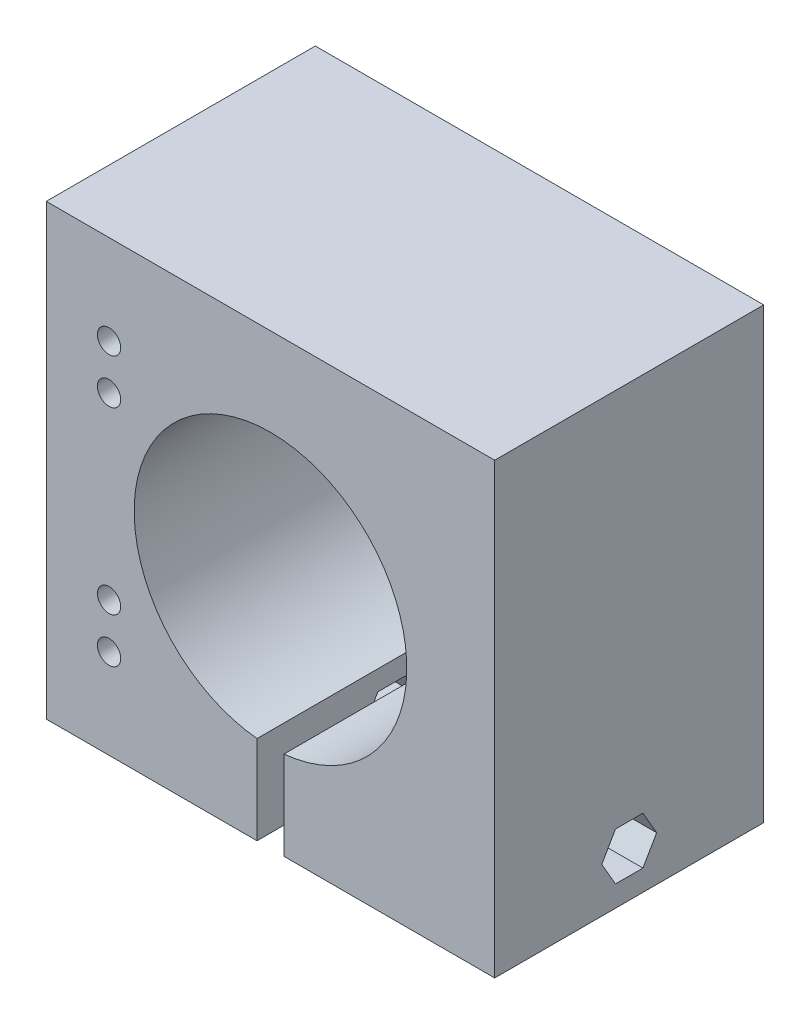
from build123d import *

# Parameters (mm, degrees)
SKETCH1_W           = 50
SKETCH1_H           = 50
SKETCH1_R           = 15.2
SKETCH1_R_2         = 1.3
BOSS_EXTRUDE1_DEPTH = 30
CUT_EXTRUDE1_REACH  = 32
SKETCH2_W           = 3
SKETCH2_H           = 11.709133009
CUT_EXTRUDE2_DEPTH  = 54
CUT_EXTRUDE3_DEPTH  = 5


with BuildPart() as part:
    # Sketch1 → Boss-Extrude1 (new body)
    with BuildSketch(Plane.XY):
        with Locations((25, 25)):
            Rectangle(SKETCH1_W, SKETCH1_H)
        with Locations((25, 25)):
            Circle(SKETCH1_R, mode=Mode.SUBTRACT)
        with Locations((7, 15)):
            Circle(SKETCH1_R_2, mode=Mode.SUBTRACT)
        with Locations((7, 40)):
            Circle(SKETCH1_R_2, mode=Mode.SUBTRACT)
        with Locations((7, 10)):
            Circle(SKETCH1_R_2, mode=Mode.SUBTRACT)
        with Locations((7, 35)):
            Circle(SKETCH1_R_2, mode=Mode.SUBTRACT)
    extrude(amount=BOSS_EXTRUDE1_DEPTH)

    # Sketch2 → Cut-Extrude1 (cut, up to next)
    with BuildSketch(Plane.XY.offset(30), mode=Mode.PRIVATE) as cut_extrude1_sk1:
        with Locations((25, 5.854566505)):
            Rectangle(SKETCH2_W, SKETCH2_H)
    cut_extrude1_tool1 = extrude(cut_extrude1_sk1.sketch, amount=-CUT_EXTRUDE1_REACH, mode=Mode.PRIVATE) & part.part
    add(cut_extrude1_tool1.solids().sort_by_distance((25, 5.854567, 30))[0], mode=Mode.SUBTRACT)

    # Sketch3 → Cut-Extrude2 (cut)
    with BuildSketch(Plane(origin=(50, 0, 0), x_dir=(0, 0, -1), z_dir=(1, 0, 0))):
        Polygon((-11.940043573, 5), (-13.470021787, 7.65), (-16.529978213, 7.65), (-18.059956427, 5), (-16.529978213, 2.35), (-13.470021787, 2.35), align=None)
    extrude(amount=-CUT_EXTRUDE2_DEPTH, mode=Mode.SUBTRACT)

    # Sketch4 → Cut-Extrude3 (cut)
    with BuildSketch(Plane.ZY):
        Polygon((19.792007234, 5), (17.396003617, 9.15), (12.603996383, 9.15), (10.207992766, 5), (12.603996383, 0.85), (17.396003617, 0.85), align=None)
    extrude(amount=-CUT_EXTRUDE3_DEPTH, mode=Mode.SUBTRACT)


solid = part.part
